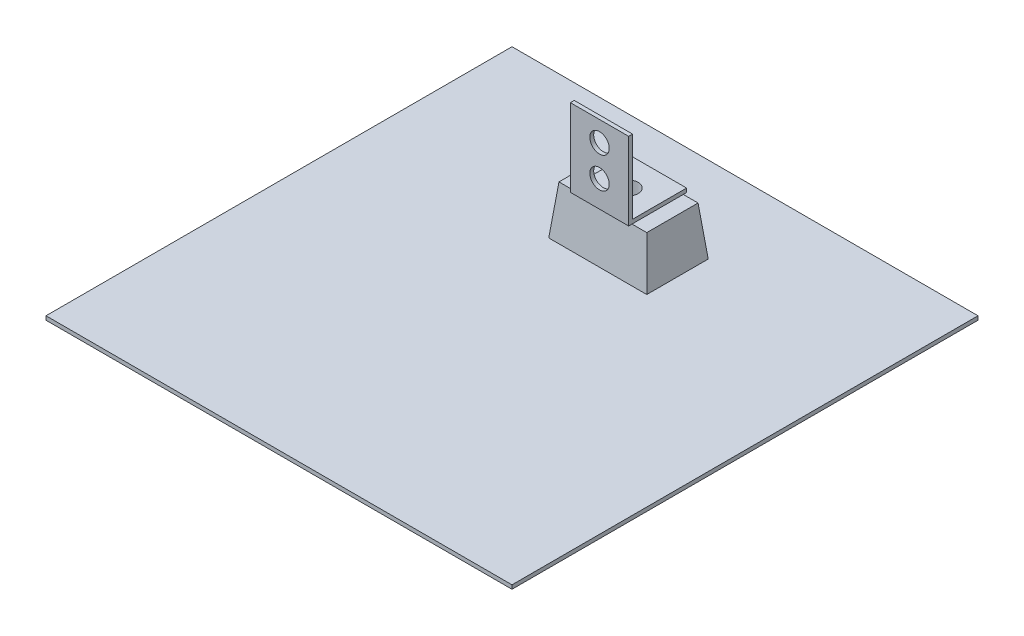
from build123d import *

# Parameters (mm, degrees)
SKETCH1_W                = 304.8
SKETCH1_H                = 304.8
BOSS_EXTRUDE1_DEPTH      = 2.54
SKETCH2_W                = 64.109804122
SKETCH2_H                = 40.213084064
BOSS_EXTRUDE2_DEPTH      = 31.75
BOSS_EXTRUDE2_TAPER      = 6
SKETCH3_R                = 6.35
CUT_EXTRUDE1_DEPTH       = 25.4
BOSS_EXTRUDE3_DEPTH      = 19.05
BOSS_EXTRUDE3_DEPTH_BACK = 19.05
SKETCH5_R                = 6.35
CUT_EXTRUDE2_DEPTH       = 50.8
SKETCH6_R                = 6.35
CUT_EXTRUDE3_DEPTH       = 19.05


with BuildPart() as part:
    # Sketch1 → Boss-Extrude1 (new body)
    with BuildSketch(Plane(origin=(0, 0, 0), x_dir=(1, 0, 0), z_dir=(0, 1, 0))):
        with Locations((152.4, 152.4)):
            Rectangle(SKETCH1_W, SKETCH1_H)
    extrude(amount=BOSS_EXTRUDE1_DEPTH)

    # Sketch2 → Boss-Extrude2 (add)
    with BuildSketch(Plane(origin=(0, 2.54, 0), x_dir=(1, 0, 0), z_dir=(0, 1, 0))):
        with Locations((152.4, 228.6)):
            Rectangle(SKETCH2_W, SKETCH2_H)
    extrude(amount=BOSS_EXTRUDE2_DEPTH, taper=BOSS_EXTRUDE2_TAPER)

    # Sketch3 → Cut-Extrude1 (cut)
    with BuildSketch(Plane(origin=(0, 34.29, 0), x_dir=(1, 0, 0), z_dir=(0, 1, 0))):
        with Locations((152.4, 228.6)):
            Circle(SKETCH3_R)
    extrude(amount=-CUT_EXTRUDE1_DEPTH, mode=Mode.SUBTRACT)

    # Sketch4 → Boss-Extrude3 (add, two sides)
    with BuildSketch(Plane(origin=(152.4, 0, 0), x_dir=(0, 0, -1), z_dir=(1, 0, 0))) as boss_extrude3_sk:
        Polygon((209.648741009, 34.29), (247.551258991, 34.29), (247.551258991, 36.83), (212.188741009, 36.83), (212.188741009, 77.47), (212.188741009, 85.09), (209.648741009, 85.09), align=None)
    extrude(amount=BOSS_EXTRUDE3_DEPTH)
    extrude(boss_extrude3_sk.sketch, amount=-BOSS_EXTRUDE3_DEPTH_BACK)

    # Sketch5 → Cut-Extrude2 (cut)
    with BuildSketch(Plane(origin=(0, 36.83, 0), x_dir=(1, 0, 0), z_dir=(0, 1, 0))):
        with Locations((152.4, 228.6)):
            Circle(SKETCH5_R)
    extrude(amount=-CUT_EXTRUDE2_DEPTH, mode=Mode.SUBTRACT)

    # Sketch6 → Cut-Extrude3 (cut)
    with BuildSketch(Plane(origin=(0, 0, -212.188741009), x_dir=(-1, 0, 0), z_dir=(0, 0, -1))):
        with Locations((-152.4, 71.864665845)):
            Circle(SKETCH6_R)
        with Locations((-152.4, 51.544665845)):
            Circle(SKETCH6_R)
    extrude(amount=-CUT_EXTRUDE3_DEPTH, mode=Mode.SUBTRACT)


solid = part.part
